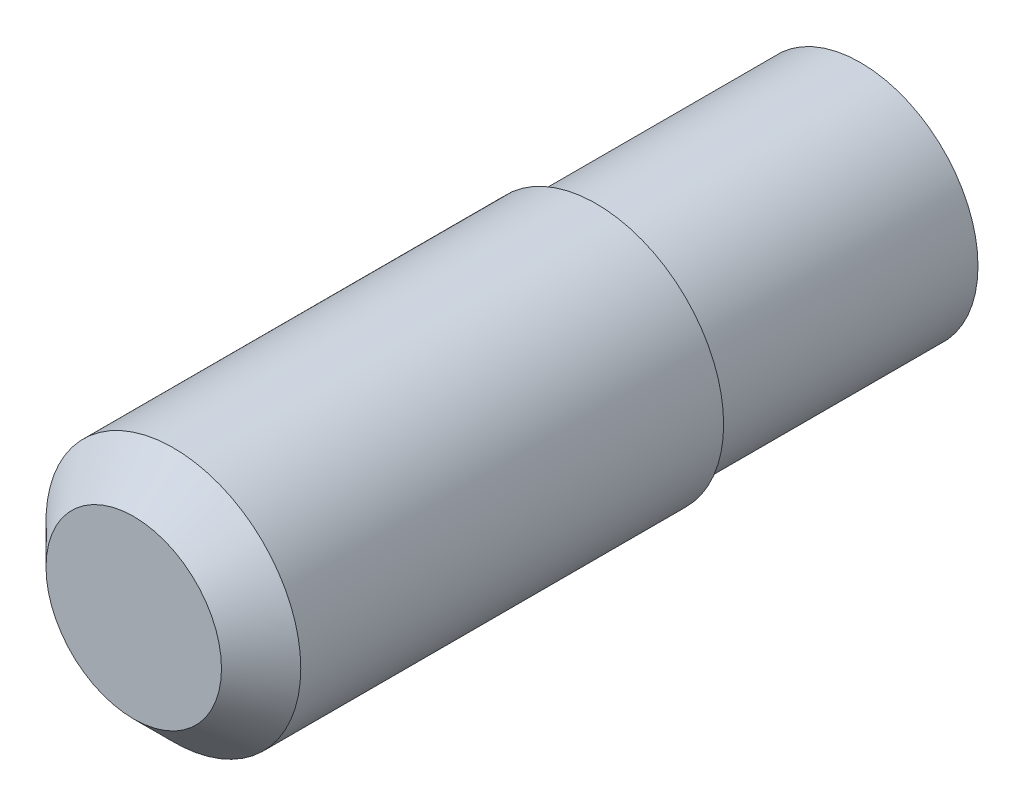
from build123d import *

# Parameters (mm, degrees)
SKETCH1_R           = 5.926666667
BOSS_EXTRUDE1_DEPTH = 13.333333333
SKETCH2_R           = 6.426666667
BOSS_EXTRUDE2_DEPTH = 16.666666667
SKETCH3_R           = 6.426666667
BOSS_EXTRUDE3_DEPTH = 6.666666667
CHAMFER1_SIZE       = 2


with BuildPart() as part:
    # Sketch1 → Boss-Extrude1 (new body)
    with BuildSketch(Plane.XY):
        with Locations((137.157808662, 37.171292193)):
            Circle(SKETCH1_R)
    extrude(amount=BOSS_EXTRUDE1_DEPTH)

    # Sketch2 → Boss-Extrude2 (add)
    with BuildSketch(Plane.XY.offset(13.333333333)):
        with Locations((137.157808662, 37.171292193)):
            Circle(SKETCH2_R)
    extrude(amount=BOSS_EXTRUDE2_DEPTH)

    # Sketch3 → Boss-Extrude3 (add)
    with BuildSketch(Plane.XY.offset(30)):
        with Locations((137.157808662, 37.171292193)):
            Circle(SKETCH3_R)
    extrude(amount=BOSS_EXTRUDE3_DEPTH)

    # Chamfer1
    chamfer1_edges = [part.edges().sort_by_distance(p)[0] for p in [
        (130.731141995, 37.171292193, 36.666666667),
    ]]
    chamfer(chamfer1_edges, length=CHAMFER1_SIZE)


solid = part.part
